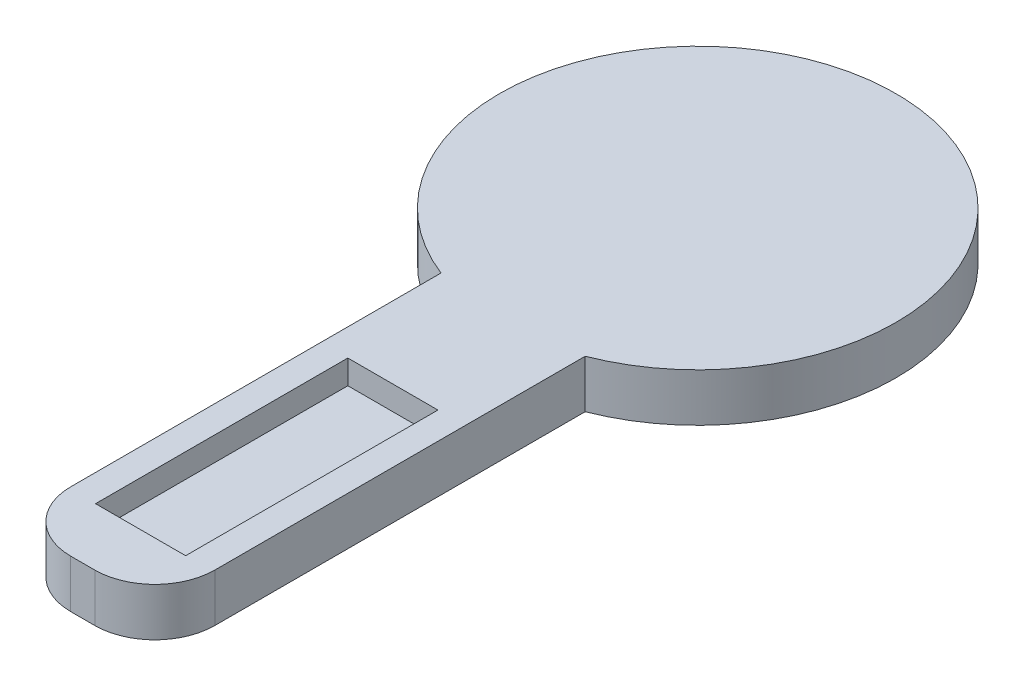
from build123d import *

# Parameters (mm, degrees)
SKETCH1_W           = 12
SKETCH1_H           = 60
BOSS_EXTRUDE1_DEPTH = 4
SKETCH2_W           = 7.5
SKETCH2_H           = 21
CUT_EXTRUDE1_DEPTH  = 2
SKETCH4_R           = 3.5
BOSS_EXTRUDE2_DEPTH = 1
SKETCH5_R           = 16.5
BOSS_EXTRUDE3_DEPTH = 4
FILLET2_R           = 5


with BuildPart() as part:
    # Sketch1 → Boss-Extrude1 (new body)
    with BuildSketch(Plane(origin=(0, 0, 0), x_dir=(1, 0, 0), z_dir=(0, 1, 0))):
        Rectangle(SKETCH1_W, SKETCH1_H)
    extrude(amount=BOSS_EXTRUDE1_DEPTH)

    # Sketch2 → Cut-Extrude1 (cut)
    with BuildSketch(Plane(origin=(0, 4, 0), x_dir=(1, 0, 0), z_dir=(0, 1, 0))):
        with Locations((0, -14.685)):
            Rectangle(SKETCH2_W, SKETCH2_H)
    extrude(amount=-CUT_EXTRUDE1_DEPTH, mode=Mode.SUBTRACT)

    # Sketch4 → Boss-Extrude2 (add)
    with BuildSketch(Plane.XZ):
        with Locations((0, 21.18)):
            Circle(SKETCH4_R)
    extrude(amount=BOSS_EXTRUDE2_DEPTH)

    # Sketch5 → Boss-Extrude3 (add)
    with BuildSketch(Plane(origin=(0, 4, 0), x_dir=(1, 0, 0), z_dir=(0, 1, 0))):
        with Locations((0, 21.19)):
            Circle(SKETCH5_R)
    extrude(amount=-BOSS_EXTRUDE3_DEPTH)

    # Fillet2
    fillet2_edges = [part.edges().sort_by_distance(p)[0] for p in [
        (6, 2, 30),
        (-6, 2, 30),
    ]]
    fillet(fillet2_edges, radius=FILLET2_R)


solid = part.part
